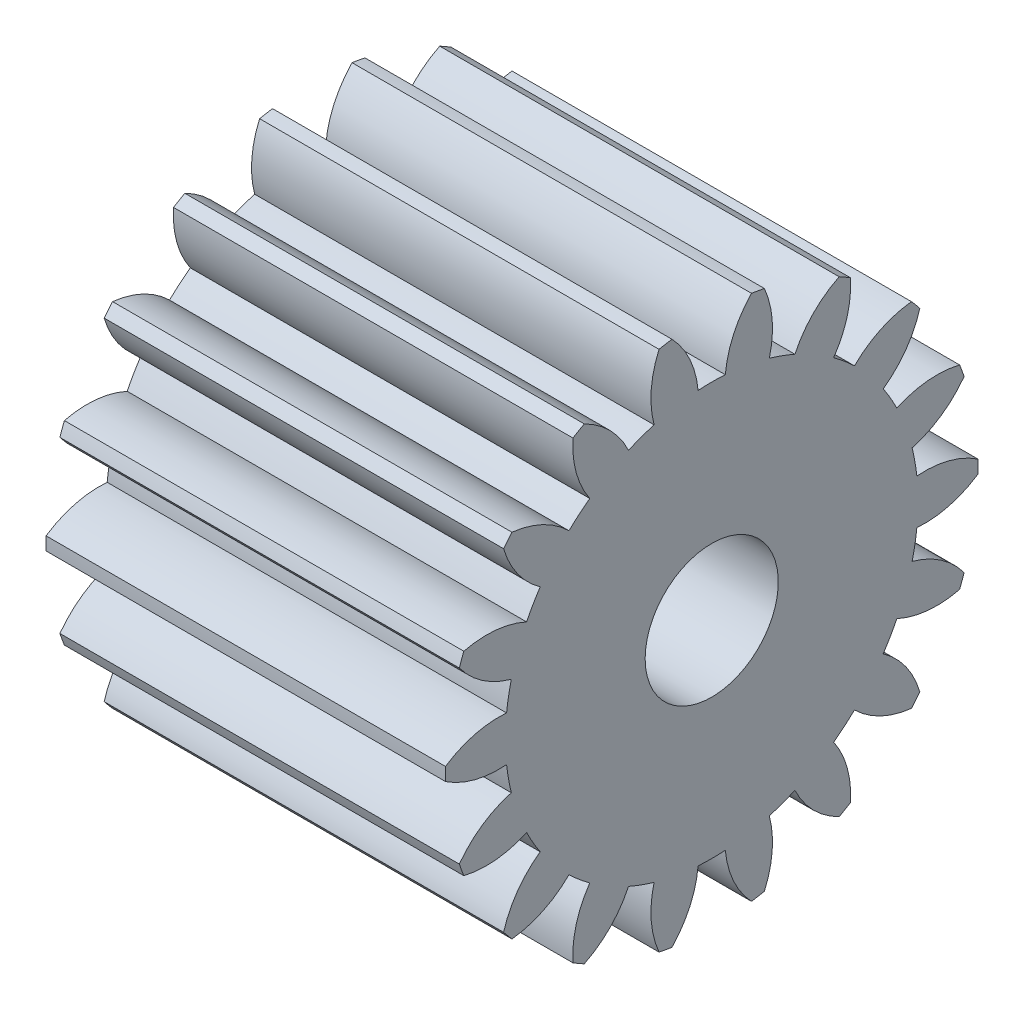
from build123d import *

# Parameters (mm, degrees)
BASPROSKE_W     = 15
BASPROSKE_H     = 10
TOOTHCUT_DEPTH  = 21.615528128
TEETHCUTS_COUNT = 18
TEETHCUTS_ANGLE = 340
BORSKE_R        = 2.5
BORE_DEPTH      = 50.0000508


with BuildPart() as part:
    # BasProSke → Base-Revolve (revolve)
    with BuildSketch(Plane(origin=(0, 0, 0), x_dir=(1, 0, 0), z_dir=(0, 1, 0)), mode=Mode.PRIVATE) as base_revolve_sk:
        with Locations((7.5, 5)):
            Rectangle(BASPROSKE_W, BASPROSKE_H)
    revolve(base_revolve_sk.sketch.rotate(Axis((-10, 0, 0), (1, 0, 0)), 180), axis=Axis((-10, 0, 0), (1, 0, 0)))

    # TooCutSke → ToothCut (cut, through all)
    with BuildSketch(Plane(origin=(0, 0, 0), x_dir=(0, 0, -1), z_dir=(1, 0, 0))):
        with BuildLine():
            ThreePointArc((0.510641536, 7.732156635), (0, 7.749), (-0.510641536, 7.732156635))
            ThreePointArc((-0.510641536, 7.732156635), (-0.82619259, 8.907320741), (-1.515208602, 9.910236529))
            ThreePointArc((-1.515208602, 9.910236529), (0, 10.0254), (1.515208602, 9.910236529))
            ThreePointArc((1.515208602, 9.910236529), (0.82619259, 8.907320741), (0.510641536, 7.732156635))
        make_face()
    toothcut = extrude(amount=TOOTHCUT_DEPTH, mode=Mode.SUBTRACT)

    # TeethCuts: ToothCut ×18 about axis
    teethcuts_axis = Axis((-10, 0, 0), (1, 0, 0))
    for i in range(1, TEETHCUTS_COUNT):
        add(toothcut.rotate(teethcuts_axis, i * TEETHCUTS_ANGLE / (TEETHCUTS_COUNT - 1)), mode=Mode.SUBTRACT)

    # BorSke → Bore (cut, symmetric)
    with BuildSketch(Plane(origin=(0, 0, 0), x_dir=(0, 0, -1), z_dir=(1, 0, 0))):
        with Locations(Location((0, 0, 0), (0, 0, 180))):
            Circle(BORSKE_R)
    extrude(amount=BORE_DEPTH, both=True, mode=Mode.SUBTRACT)


solid = part.part
